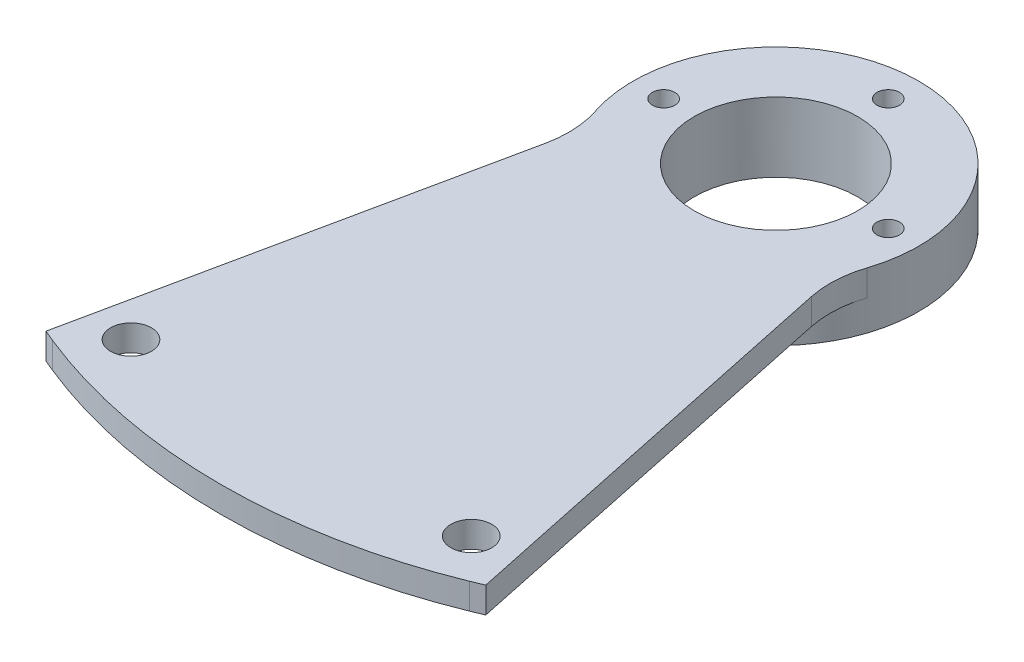
from build123d import *

# Parameters (mm, degrees)
SKETCH1_R           = 1.999999943
SKETCH1_R_2         = 1.1
SKETCH1_R_3         = 8
BOSS_EXTRUDE1_DEPTH = 2.54
FILLET2_R           = 10
BOSS_EXTRUDE2_START = -2.999994
SKETCH1_4_R         = 8
SKETCH1_4_R_2       = 1.1
BOSS_EXTRUDE2_DEPTH = 2.999994
BOSS_EXTRUDE3_START = 1.27
SKETCH2_R           = 9
SKETCH2_R_2         = 8
BOSS_EXTRUDE3_DEPTH = 1.27


with BuildPart() as part:
    # Sketch1 → Boss-Extrude1 (new body)
    with BuildSketch(Plane(origin=(0, 0, 0), x_dir=(1, 0, 0), z_dir=(0, 1, 0))):
        with BuildLine():
            Line((20.411129853, -60.145086441), (21.536156884, -59.674942586))
            Line((21.536156884, -59.674942586), (12.379162196, -16.260133485))
            ThreePointArc((12.379162196, -16.260133485), (0, 4.278699998), (-12.379162196, -16.260133485))
            Line((-12.379162196, -16.260133485), (-21.536156884, -59.674942586))
            Line((-21.536156884, -59.674942586), (-20.411129853, -60.145086441))
            ThreePointArc((-20.411129853, -60.145086441), (0, -64.119576268), (20.411129853, -60.145086441))
        make_face()
        with Locations((-16.665975394, -56.223288884)):
            Circle(SKETCH1_R, mode=Mode.SUBTRACT)
        with Locations((16.665975394, -56.223288884)):
            Circle(SKETCH1_R, mode=Mode.SUBTRACT)
        with Locations((-11, -9.721300002)):
            Circle(SKETCH1_R_2, mode=Mode.SUBTRACT)
        with Locations((0, -9.721300002)):
            Circle(SKETCH1_R_3, mode=Mode.SUBTRACT)
        with Locations((0, 1.278699998)):
            Circle(SKETCH1_R_2, mode=Mode.SUBTRACT)
        with Locations((11, -9.721300002)):
            Circle(SKETCH1_R_2, mode=Mode.SUBTRACT)
    extrude(amount=BOSS_EXTRUDE1_DEPTH)

    # Fillet2
    fillet2_edges = [part.edges().sort_by_distance(p)[0] for p in [
        (-12.379162196, 1.27, 16.260133485),
        (12.379162196, 1.27, 16.260133485),
    ]]
    fillet(fillet2_edges, radius=FILLET2_R)

    # Sketch1_4 → Boss-Extrude2 (add)
    with BuildSketch(Plane(origin=(0, 0, 0), x_dir=(1, 0, 0), z_dir=(0, 1, 0)).offset(BOSS_EXTRUDE2_START)):
        with BuildLine():
            ThreePointArc((-12.379162196, -16.260133485), (0, -23.721300002), (12.379162196, -16.260133485))
            ThreePointArc((12.379162196, -16.260133485), (13.588750324, -13.089662308), (14, -9.721300002))
            ThreePointArc((14, -9.721300002), (-3.368362306, 3.867450323), (-12.379162196, -16.260133485))
        make_face()
        with BuildLine():
            ThreePointArc((-9.9, -9.721300002), (-10.307077747, -10.575617712), (-11.22701591, -10.797619553))
            ThreePointArc((-11.22701591, -10.797619553), (-11.692922253, -8.866982291), (-9.9, -9.721300002))
        make_face(mode=Mode.SUBTRACT)
        with Locations((0, -9.721300002)):
            Circle(SKETCH1_4_R, mode=Mode.SUBTRACT)
        with Locations((0, 1.278699998)):
            Circle(SKETCH1_4_R_2, mode=Mode.SUBTRACT)
        with BuildLine():
            ThreePointArc((12.1, -9.721300002), (11.854317711, -10.414222255), (11.22701591, -10.797619553))
            ThreePointArc((11.22701591, -10.797619553), (10.145682289, -9.028377748), (12.1, -9.721300002))
        make_face(mode=Mode.SUBTRACT)
    extrude(amount=BOSS_EXTRUDE2_DEPTH)

    # Sketch2 → Boss-Extrude3 (add)
    with BuildSketch(Plane.XZ.offset(2.999994).offset(BOSS_EXTRUDE3_START)):
        with Locations((0, 9.721300002)):
            Circle(SKETCH2_R)
        with Locations((0, 9.721300002)):
            Circle(SKETCH2_R_2, mode=Mode.SUBTRACT)
    extrude(amount=-BOSS_EXTRUDE3_DEPTH)


solid = part.part
